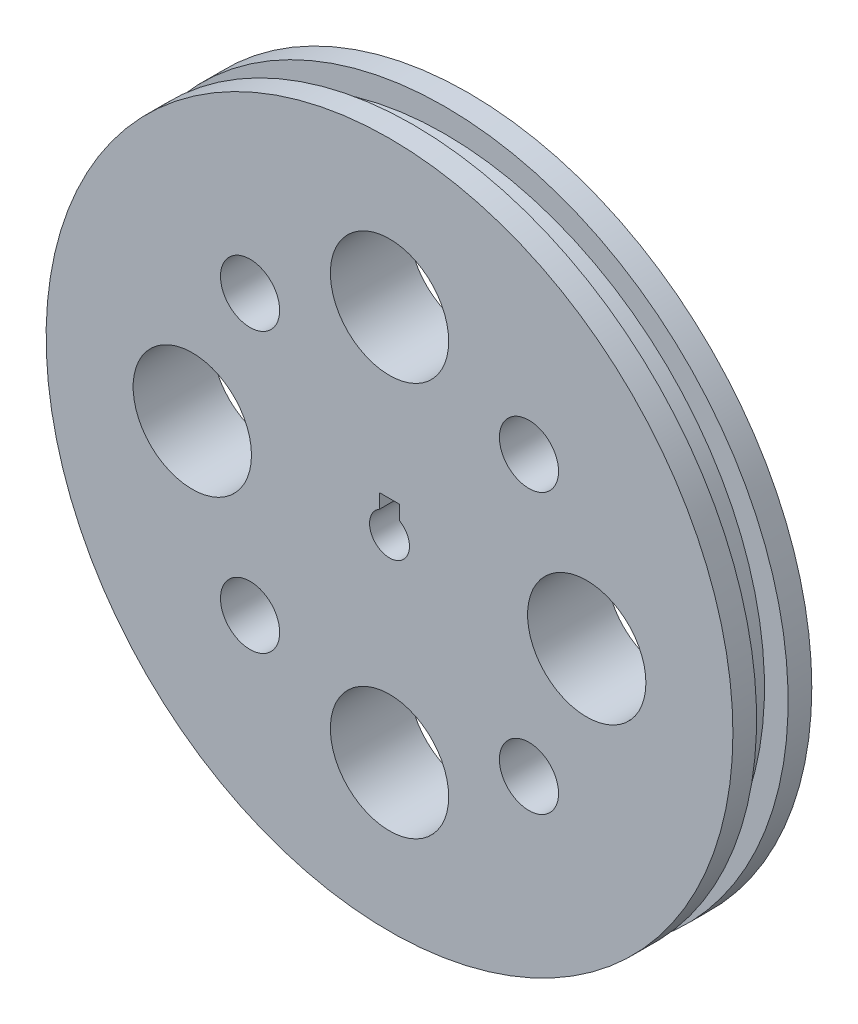
from build123d import *

# Parameters (mm, degrees)
SKETCH1_R           = 110.567781149
BOSS_EXTRUDE1_DEPTH = 25.4
SKETCH2_R           = 19.05
SKETCH2_R_2         = 9.525
CUT_EXTRUDE3_DEPTH  = 140.716
CUT_EXTRUDE4_DEPTH  = 134.112
SKETCH6_W           = 10.16
SKETCH6_H           = 7.62


with BuildPart() as part:
    # Sketch1 → Boss-Extrude1 (new body)
    with BuildSketch(Plane.XY):
        Circle(SKETCH1_R)
    extrude(amount=BOSS_EXTRUDE1_DEPTH)

    # Sketch2 → Cut-Extrude3 (cut)
    with BuildSketch(Plane.XY.offset(25.4)):
        with Locations((0, 63.5)):
            Circle(SKETCH2_R)
        with Locations((63.5, 0)):
            Circle(SKETCH2_R)
        with Locations((44.901280605, -44.901280605)):
            Circle(SKETCH2_R_2)
        with Locations((0, -63.5)):
            Circle(SKETCH2_R)
        with Locations((44.901280605, 44.901280605)):
            Circle(SKETCH2_R_2)
        with Locations((-44.901280605, -44.901280605)):
            Circle(SKETCH2_R_2)
        with Locations((-63.5, 0)):
            Circle(SKETCH2_R)
        with Locations((-44.901280605, 44.901280605)):
            Circle(SKETCH2_R_2)
    extrude(amount=-CUT_EXTRUDE3_DEPTH, mode=Mode.SUBTRACT)

    # Sketch5 → Cut-Extrude4 (cut)
    with BuildSketch(Plane.XY.offset(25.4)):
        with BuildLine():
            Line((-3.175, 10.16), (3.175, 10.16))
            Line((3.175, 10.16), (3.175, 5.588))
            ThreePointArc((3.175, 5.588), (0, -6.427003112), (-3.175, 5.588))
            Line((-3.175, 5.588), (-3.175, 10.16))
        make_face()
    extrude(amount=-CUT_EXTRUDE4_DEPTH, mode=Mode.SUBTRACT)

    # Sketch6 → Cut-Revolve1 (revolve, cut)
    with BuildSketch(Plane(origin=(0, 0, 0), x_dir=(0, 0, -1), z_dir=(1, 0, 0))):
        with Locations((-12.7, 106.757781149)):
            Rectangle(SKETCH6_W, SKETCH6_H)
    revolve(axis=Axis((0, 0, 0), (0, 0, 1)), mode=Mode.SUBTRACT)


solid = part.part
